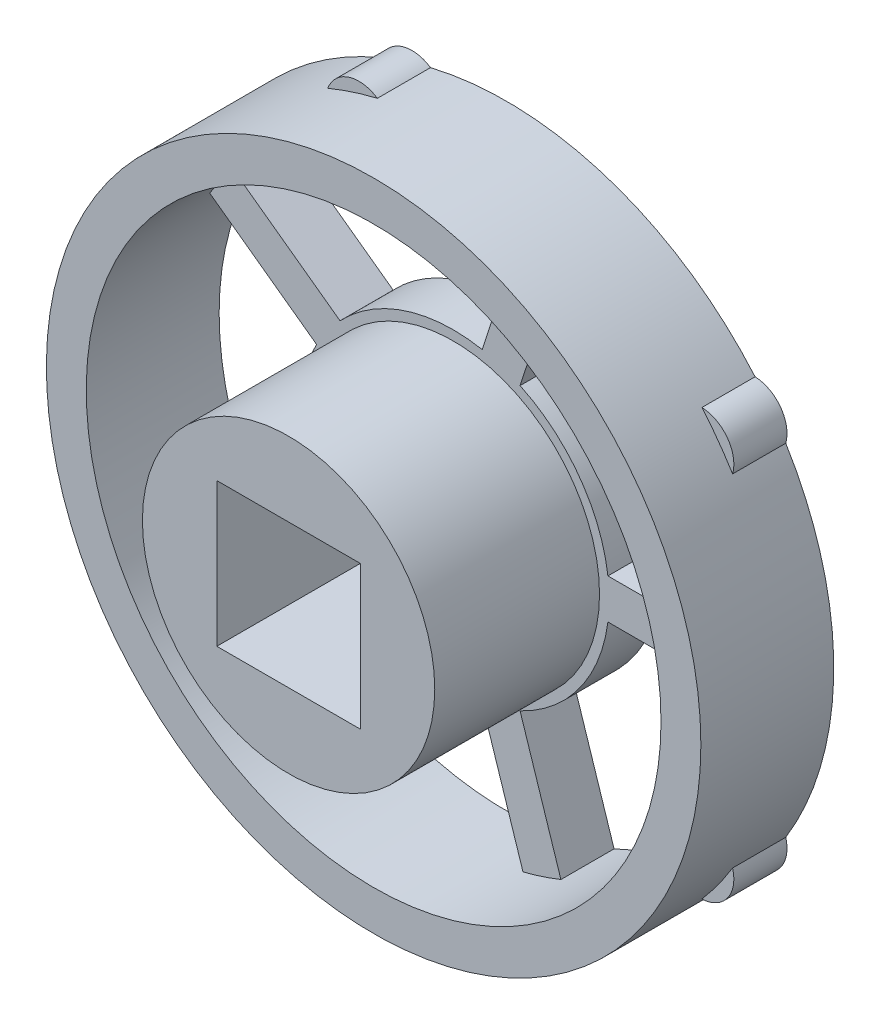
from build123d import *

# Parameters (mm, degrees)
SKETCH_1_W      = 5.4
SKETCH_1_H      = 5.4
EXTRUDE_1_DEPTH = 2
SKETCH_2_R      = 12.313072817
SKETCH_2_R_2    = 10.813072817
EXTRUDE_2_DEPTH = 3
SKETCH_3_R      = 5.5
SKETCH_3_W      = 5.4
SKETCH_3_H      = 5.4
EXTRUDE_3_DEPTH = 6.2


with BuildPart() as part:
    # 스케치1 → 보스-돌출1 (new body)
    with BuildSketch(Plane(origin=(0, 0, 0), x_dir=(0, 1, 0), z_dir=(0, 0, 1))):
        with BuildLine():
            ThreePointArc((0.981635498, 12.273880965), (0, 12.75), (-0.981635498, 12.273880965))
            ThreePointArc((-0.981635498, 12.273880965), (-7.237442612, 9.961485162), (-11.369812421, 4.726428642))
            ThreePointArc((-11.369812421, 4.726428642), (-12.125970583, 3.939966678), (-11.976496524, 2.859246968))
            ThreePointArc((-11.976496524, 2.859246968), (-11.710428139, -3.804948754), (-8.00856602, -9.352787419))
            ThreePointArc((-8.00856602, -9.352787419), (-7.494261967, -10.314966678), (-6.42024642, -10.506769157))
            ThreePointArc((-6.42024642, -10.506769157), (0, -12.313072817), (6.42024642, -10.506769157))
            ThreePointArc((6.42024642, -10.506769157), (7.494261967, -10.314966678), (8.00856602, -9.352787419))
            ThreePointArc((8.00856602, -9.352787419), (11.710428139, -3.804948754), (11.976496524, 2.859246968))
            ThreePointArc((11.976496524, 2.859246968), (12.125970583, 3.939966678), (11.369812421, 4.726428642))
            ThreePointArc((11.369812421, 4.726428642), (7.237442612, 9.961485162), (0.981635498, 12.273880965))
        make_face()
        with BuildLine():
            ThreePointArc((5.733695154, 9.167730561), (0, 10.813072817), (-5.733695154, 9.167730561))
            Line((-5.733695154, 9.167730561), (-2.811327739, 5.145436885))
            ThreePointArc((-2.811327739, 5.145436885), (0, 5.863368008), (2.811327739, 5.145436885))
            Line((2.811327739, 5.145436885), (5.733695154, 9.167730561))
        make_face(mode=Mode.SUBTRACT)
        with BuildLine():
            ThreePointArc((10.490839132, -2.620083596), (10.283843364, 3.341423262), (6.947220646, 8.286052682))
            Line((6.947220646, 8.286052682), (4.024853231, 4.263759007))
            ThreePointArc((4.024853231, 4.263759007), (5.576394352, 1.811880359), (5.762349327, -1.083704125))
            Line((5.762349327, -1.083704125), (10.490839132, -2.620083596))
        make_face(mode=Mode.SUBTRACT)
        Rectangle(SKETCH_1_W, SKETCH_1_H, mode=Mode.SUBTRACT)
        with BuildLine():
            Line((-5.298823836, -2.510288899), (-10.027313641, -4.04666837))
            ThreePointArc((-10.027313641, -4.04666837), (-6.355764734, -8.747959671), (-0.75, -10.787031276))
            Line((-0.75, -10.787031276), (-0.75, -5.815202868))
            ThreePointArc((-0.75, -5.815202868), (-3.446401244, -4.743564363), (-5.298823836, -2.510288899))
        make_face(mode=Mode.SUBTRACT)
        with BuildLine():
            Line((-4.024853231, 4.263759007), (-6.947220646, 8.286052682))
            ThreePointArc((-6.947220646, 8.286052682), (-10.283843364, 3.341423262), (-10.490839132, -2.620083596))
            Line((-10.490839132, -2.620083596), (-5.762349327, -1.083704125))
            ThreePointArc((-5.762349327, -1.083704125), (-5.576394352, 1.811880359), (-4.024853231, 4.263759007))
        make_face(mode=Mode.SUBTRACT)
        with BuildLine():
            Line((0.75, -5.815202868), (0.75, -10.787031276))
            ThreePointArc((0.75, -10.787031276), (6.355764734, -8.747959671), (10.027313641, -4.04666837))
            Line((10.027313641, -4.04666837), (5.298823836, -2.510288899))
            ThreePointArc((5.298823836, -2.510288899), (3.446401244, -4.743564363), (0.75, -5.815202868))
        make_face(mode=Mode.SUBTRACT)
    extrude(amount=EXTRUDE_1_DEPTH)

    # 스케치2 → 보스-돌출2 (add)
    with BuildSketch(Plane.XY.offset(2)):
        Circle(SKETCH_2_R)
        Circle(SKETCH_2_R_2, mode=Mode.SUBTRACT)
    extrude(amount=EXTRUDE_2_DEPTH)

    # 스케치3 → 보스-돌출3 (add)
    with BuildSketch(Plane.XY.offset(2)):
        Circle(SKETCH_3_R)
        Rectangle(SKETCH_3_W, SKETCH_3_H, mode=Mode.SUBTRACT)
    extrude(amount=EXTRUDE_3_DEPTH)


solid = part.part
